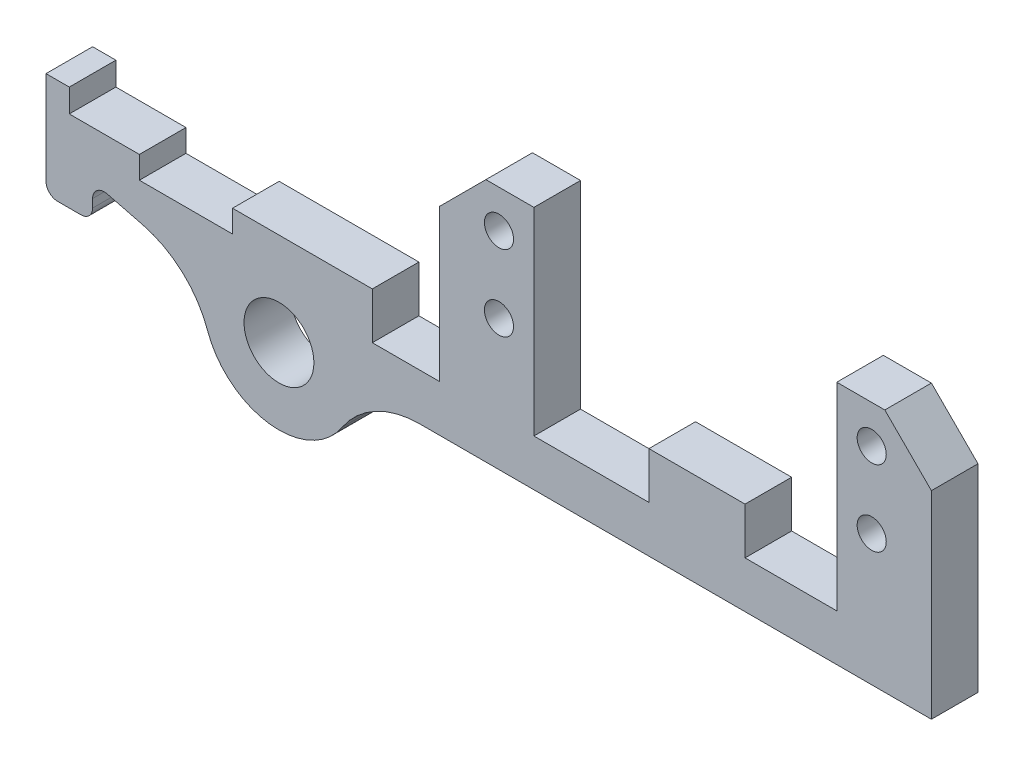
from build123d import *

# Parameters (mm, degrees)
SKETCH1_W               = 12.9
SKETCH1_H               = 6.35
BOSS_EXTRUDE1_DEPTH     = 6.35
BOSS_EXTRUDE1_2_DEPTH   = 6.35
SKETCH1_W_2             = 13.1
BOSS_EXTRUDE1_3_DEPTH   = 6.35
BOSS_EXTRUDE1_4_DEPTH   = 6.35
SKETCH2_W               = 88.9
SKETCH2_H               = 6.35
BOSS_EXTRUDE2_DEPTH     = 12.7
SKETCH3_W               = 12.9
SKETCH3_H               = 6.35
BOSS_EXTRUDE3_DEPTH     = 20.6375
CHAMFER1_SIZE           = 6.35
SKETCH4_R               = 1.984375
CUT_EXTRUDE1_DEPTH      = 7.35
SKETCH12_W              = 6.35
SKETCH12_H              = 12.7
BOSS_EXTRUDE6_DEPTH     = 0.2
SKETCH13_W              = 89.1
SKETCH13_H              = 6.35
CUT_EXTRUDE2_DEPTH      = 7.35
BOSS_EXTRUDE7_DEPTH     = 6.35
SKETCH19_R              = 10.31875
SKETCH19_R_2            = 4.7625
BOSS_EXTRUDE8_DEPTH     = 6.35
SKETCH20_R              = 4.7625
CUT_EXTRUDE3_DEPTH      = 1
CUT_EXTRUDE3_DEPTH_BACK = 7.35
FILLET2_R               = 12.7
SKETCH21_W              = 6.35
SKETCH21_H              = 6.35
BOSS_EXTRUDE9_DEPTH     = 6.35
FILLET4_R               = 1.5875
SKETCH22_W              = 12.7
SKETCH22_H              = 3.048
CUT_EXTRUDE4_DEPTH      = 7.35


with BuildPart() as part:
    # Sketch1 → Boss-Extrude1 (new body)
    with BuildSketch(Plane(origin=(0, 136.676286052, 0), x_dir=(1, 0, 0), z_dir=(0, 1, 0))):
        with Locations((-97.400963438, -57.278255958)):
            Rectangle(SKETCH1_W, SKETCH1_H)
    extrude(amount=-BOSS_EXTRUDE1_DEPTH)



with BuildPart() as body_2:
    # Sketch1 → Boss-Extrude1 2 (new body)
    with BuildSketch(Plane(origin=(0, 136.676286052, 0), x_dir=(1, 0, 0), z_dir=(0, 1, 0))):
        with Locations((-75.375963438, -57.278255958)):
            Rectangle(SKETCH1_W, SKETCH1_H)
    extrude(amount=-BOSS_EXTRUDE1_2_DEPTH)


with BuildPart() as body_3:
    # Sketch1 → Boss-Extrude1 3 (new body)
    with BuildSketch(Plane(origin=(0, 136.676286052, 0), x_dir=(1, 0, 0), z_dir=(0, 1, 0))):
        with Locations((-46.700963438, -57.278255958)):
            Rectangle(SKETCH1_W_2, SKETCH1_H)
    extrude(amount=-BOSS_EXTRUDE1_3_DEPTH)


with BuildPart() as body_4:
    # Sketch1 → Boss-Extrude1 4 (new body)
    with BuildSketch(Plane(origin=(0, 136.676286052, 0), x_dir=(1, 0, 0), z_dir=(0, 1, 0))):
        with Locations((-21.200963438, -57.278255958)):
            Rectangle(SKETCH1_W, SKETCH1_H)
    extrude(amount=-BOSS_EXTRUDE1_4_DEPTH)


with BuildPart() as part_1:
    add(part.part)

    add(body_2.part)  # Boss-Extrude2 merges body 2

    add(body_3.part)  # Boss-Extrude2 merges body 3

    add(body_4.part)  # Boss-Extrude2 merges body 4
    # Sketch2 → Boss-Extrude2 (add)
    with BuildSketch(Plane(origin=(0, 130.326286052, 0), x_dir=(-1, 0, 0), z_dir=(0, -1, 0))):
        with Locations((59.400963438, -57.278255958)):
            Rectangle(SKETCH2_W, SKETCH2_H)
    extrude(amount=BOSS_EXTRUDE2_DEPTH)

    # Sketch3 → Boss-Extrude3 (add)
    with BuildSketch(Plane(origin=(0, 136.676286052, 0), x_dir=(1, 0, 0), z_dir=(0, 1, 0))):
        with Locations((-75.375963438, -57.278255958)):
            Rectangle(SKETCH3_W, SKETCH3_H)
        with Locations((-21.200963438, -57.278255958)):
            Rectangle(SKETCH3_W, SKETCH3_H)
    extrude(amount=BOSS_EXTRUDE3_DEPTH)

    # Chamfer1
    chamfer1_edges = [part_1.edges().sort_by_distance(p)[0] for p in [
        (-81.825963438, 157.313786052, 57.278255958),
        (-14.750963438, 157.313786052, 57.278255958),
    ]]
    chamfer(chamfer1_edges, length=CHAMFER1_SIZE)

    # Sketch4 → Cut-Extrude1 (cut, through all)
    with BuildSketch(Plane.XY.offset(60.453255958)):
        with Locations((-73.688463438, 152.154411052)):
            Circle(SKETCH4_R)
        with Locations((-73.688463438, 141.835661052)):
            Circle(SKETCH4_R)
        with Locations((-22.888463438, 141.835661052)):
            Circle(SKETCH4_R)
        with Locations((-22.888463438, 152.154411052)):
            Circle(SKETCH4_R)
    extrude(amount=-CUT_EXTRUDE1_DEPTH, mode=Mode.SUBTRACT)

    # Sketch12 → Boss-Extrude6 (add)
    with BuildSketch(Plane(origin=(-14.950963438, 0, 0), x_dir=(0, 0, -1), z_dir=(1, 0, 0))):
        with Locations((-57.278255958, 123.976286052)):
            Rectangle(SKETCH12_W, SKETCH12_H)
    extrude(amount=BOSS_EXTRUDE6_DEPTH)

    # Sketch13 → Cut-Extrude2 (cut, through all)
    with BuildSketch(Plane.XY.offset(60.453255958)):
        with Locations((-59.300963438, 120.801286052)):
            Rectangle(SKETCH13_W, SKETCH13_H)
    extrude(amount=-CUT_EXTRUDE2_DEPTH, mode=Mode.SUBTRACT)

    # Sketch14 → Boss-Extrude7 (add)
    with BuildSketch(Plane.XY.offset(60.453255958)):
        Polygon((-132.250963468, 139.851286052), (-135.425963468, 139.851286052), (-135.425963468, 131.913786052), (-103.850963438, 123.976286052), (-103.850963438, 136.676286052), (-132.250963468, 136.676286052), align=None)
    extrude(amount=-BOSS_EXTRUDE7_DEPTH)

    # Sketch19 → Boss-Extrude8 (add)
    with BuildSketch(Plane.XY.offset(60.453255958)):
        with Locations((-103.675963468, 123.976286052)):
            Circle(SKETCH19_R)
        with Locations((-103.675963468, 123.976286052)):
            Circle(SKETCH19_R_2, mode=Mode.SUBTRACT)
    extrude(amount=-BOSS_EXTRUDE8_DEPTH)

    # Sketch20 → Cut-Extrude3 (cut, two sides)
    with BuildSketch(Plane.XY.offset(60.453255958)) as cut_extrude3_sk:
        with Locations((-103.675963468, 123.976286052)):
            Circle(SKETCH20_R)
    extrude(amount=CUT_EXTRUDE3_DEPTH, mode=Mode.SUBTRACT)
    extrude(cut_extrude3_sk.sketch, amount=-CUT_EXTRUDE3_DEPTH_BACK, mode=Mode.SUBTRACT)

    # Fillet2
    fillet2_edges = [part_1.edges().sort_by_distance(p)[0] for p in [
        (-113.693666461, 126.450599755, 57.278255958),
        (-93.357213468, 123.976286052, 57.278255958),
    ]]
    fillet(fillet2_edges, radius=FILLET2_R)

    # Sketch21 → Boss-Extrude9 (add)
    with BuildSketch(Plane.XY.offset(60.453255958)):
        with Locations((-132.250963468, 128.738786052)):
            Rectangle(SKETCH21_W, SKETCH21_H)
    extrude(amount=-BOSS_EXTRUDE9_DEPTH)

    # Fillet4
    fillet4_edges = [part_1.edges().sort_by_distance(p)[0] for p in [
        (-129.075963468, 130.317487558, 57.278255958),
        (-129.075963468, 125.563786052, 57.278255958),
        (-135.425963468, 125.563786052, 57.278255958),
    ]]
    fillet(fillet4_edges, radius=FILLET4_R)

    # Sketch22 → Cut-Extrude4 (cut, through all)
    with BuildSketch(Plane.XY.offset(60.453255958)):
        with Locations((-116.350963438, 135.152286052)):
            Rectangle(SKETCH22_W, SKETCH22_H)
    extrude(amount=-CUT_EXTRUDE4_DEPTH, mode=Mode.SUBTRACT)


solid = part_1.part
